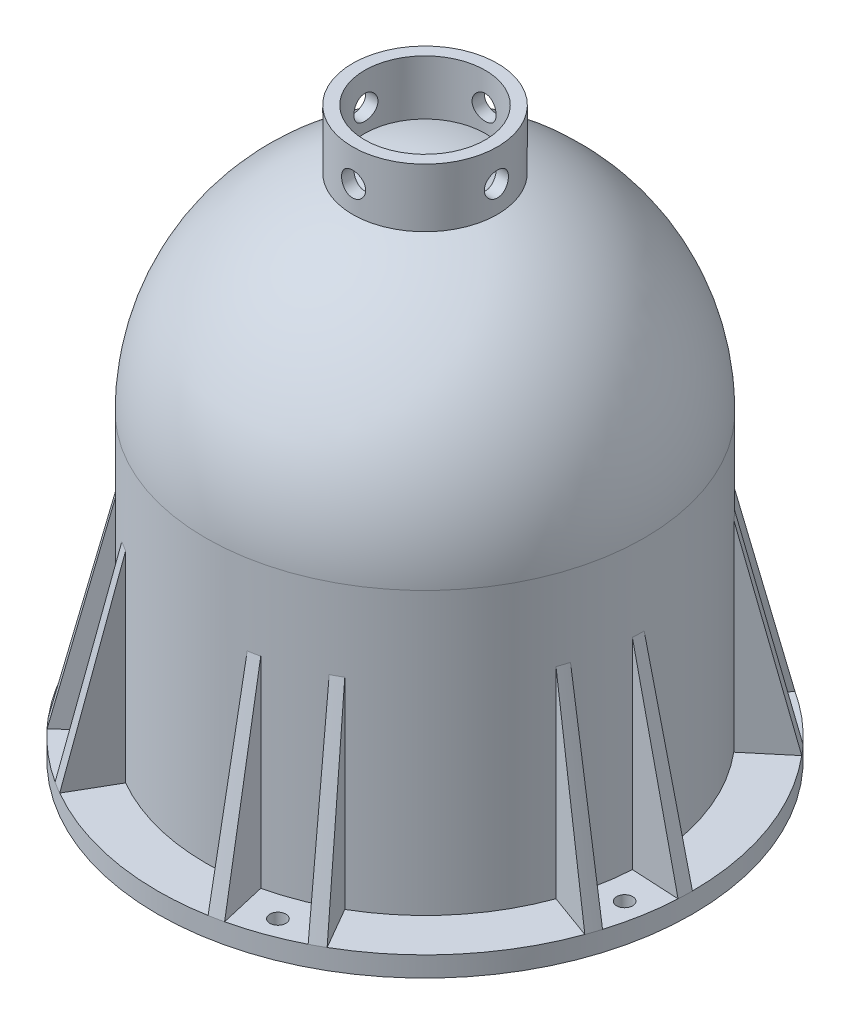
from build123d import *

# Parameters (mm, degrees)
REVOLVE2_ANGLE           = 3
CIRPATTERN1_COUNT        = 2
CIRPATTERN1_ANGLE        = 17
CUT_EXTRUDE1_REACH       = 158.028
SKETCH3_R                = 2
CIRPATTERN2_COUNT        = 6
CIRPATTERN2_COPY_1_ANGLE = 3
CIRPATTERN2_COPY_2_ANGLE = 3
CIRPATTERN2_COPY_3_ANGLE = 3
CIRPATTERN2_COPY_4_ANGLE = 3
CIRPATTERN2_COPY_5_ANGLE = 3
BOSS_EXTRUDE1_REACH      = 122.289
BOSS_EXTRUDE1_END_RADIUS = 50.5
SKETCH4_R                = 1.25
CIRPATTERN3_COUNT        = 4
BOSS_EXTRUDE2_REACH      = 171.486
BOSS_EXTRUDE2_END_RADIUS = 54.5
SKETCH5_R                = 18
SKETCH5_R_2              = 15
SKETCH6_R                = 3
CUT_EXTRUDE2_DEPTH       = 121.289234764
CIRPATTERN4_COUNT        = 2
CIRPATTERN4_ANGLE        = 90


with BuildPart() as part:
    # Sketch1 → Revolve1 (revolve)
    with BuildSketch(Plane.XY, mode=Mode.PRIVATE) as revolve1_sk:
        with BuildLine():
            Line((54.5, 0), (54.5, -70))
            Line((54.5, -70), (66.5, -70))
            Line((66.5, -70), (66.5, -75))
            Line((66.5, -75), (50.5, -75))
            Line((50.5, -75), (50.5, -70))
            Line((50.5, -70), (50.5, 0))
            ThreePointArc((50.5, 0), (35.70889245, 35.70889245), (0, 50.5))
            Line((0, 50.5), (0, 54.5))
            ThreePointArc((0, 54.5), (38.537319575, 38.537319575), (54.5, 0))
        make_face()
    revolve(revolve1_sk.sketch.rotate(Axis((0, 98.537756866, 0), (0, -1, 0)), 90), axis=Axis((0, 98.537756866, 0), (0, -1, 0)))

    # Sketch2 → Revolve2 (revolve)
    with BuildSketch(Plane.XY):
        Polygon((54.5, -20), (66.5, -70), (54.5, -70), align=None)
    revolve2 = revolve(axis=Axis((0, 98.537756866, 0), (0, -1, 0)), revolution_arc=REVOLVE2_ANGLE)

    # CirPattern1: Revolve2 ×2 about axis
    cirpattern1_axis = Axis((0, 0, 0), (0, -1, 0))
    for i in range(1, CIRPATTERN1_COUNT):
        add(revolve2.rotate(cirpattern1_axis, i * CIRPATTERN1_ANGLE / (CIRPATTERN1_COUNT - 1)))

    # Sketch3 → Cut-Extrude1 (cut, up to next)
    with BuildSketch(Plane(origin=(0, -70, 0), x_dir=(1, 0, 0), z_dir=(0, 1, 0)), mode=Mode.PRIVATE) as cut_extrude1_sk1:
        with Locations(Location((60.271959422, -10.627572626, 0), (0, 0, 270))):
            Circle(SKETCH3_R)
    cut_extrude1_tool1 = extrude(cut_extrude1_sk1.sketch, amount=-CUT_EXTRUDE1_REACH, mode=Mode.PRIVATE) & part.part
    cut_extrude1 = cut_extrude1_tool1.solids().sort_by_distance((60.271959, -70, 10.627573))[0]
    add(cut_extrude1, mode=Mode.SUBTRACT)

    # CirPattern2: Revolve2, Cut-Extrude1 ×6 about axis
    cirpattern2_axis = Axis((0, 0, 0), (0, 1, 0))
    add([revolve2.rotate(cirpattern2_axis, i * 360 / CIRPATTERN2_COUNT) for i in range(1, CIRPATTERN2_COUNT)])
    add([cut_extrude1.rotate(cirpattern2_axis, i * 360 / CIRPATTERN2_COUNT) for i in range(1, CIRPATTERN2_COUNT)], mode=Mode.SUBTRACT)

    # CirPattern2 copy 1 sketch → CirPattern2 copy 1 (revolve)
    with BuildSketch(Plane(origin=(0, 0, 0), x_dir=(0.7313537016191711, 0, -0.6819983600624979), z_dir=(0.6819983600624979, 0, 0.7313537016191711))):
        Polygon((54.5, -20), (66.5, -70), (54.5, -70), align=None)
    revolve(axis=Axis((0, 98.537756866, 0), (0, -1, 0)), revolution_arc=CIRPATTERN2_COPY_1_ANGLE)

    # CirPattern2 copy 2 sketch → CirPattern2 copy 2 (revolve)
    with BuildSketch(Plane(origin=(0, 0, 0), x_dir=(-0.2249510543438641, 0, -0.9743700647852354), z_dir=(0.9743700647852354, 0, -0.2249510543438641))):
        Polygon((54.5, -20), (66.5, -70), (54.5, -70), align=None)
    revolve(axis=Axis((0, 98.537756866, 0), (0, -1, 0)), revolution_arc=CIRPATTERN2_COPY_2_ANGLE)

    # CirPattern2 copy 3 sketch → CirPattern2 copy 3 (revolve)
    with BuildSketch(Plane(origin=(0, 0, 0), x_dir=(-0.9563047559630353, 0, -0.2923717047227375), z_dir=(0.2923717047227375, 0, -0.9563047559630353))):
        Polygon((54.5, -20), (66.5, -70), (54.5, -70), align=None)
    revolve(axis=Axis((0, 98.537756866, 0), (0, -1, 0)), revolution_arc=CIRPATTERN2_COPY_3_ANGLE)

    # CirPattern2 copy 4 sketch → CirPattern2 copy 4 (revolve)
    with BuildSketch(Plane(origin=(0, 0, 0), x_dir=(-0.7313537016191713, 0, 0.6819983600624976), z_dir=(-0.6819983600624976, 0, -0.7313537016191713))):
        Polygon((54.5, -20), (66.5, -70), (54.5, -70), align=None)
    revolve(axis=Axis((0, 98.537756866, 0), (0, -1, 0)), revolution_arc=CIRPATTERN2_COPY_4_ANGLE)

    # CirPattern2 copy 5 sketch → CirPattern2 copy 5 (revolve)
    with BuildSketch(Plane(origin=(0, 0, 0), x_dir=(0.22495105434386448, 0, 0.9743700647852354), z_dir=(-0.9743700647852354, 0, 0.22495105434386448))):
        Polygon((54.5, -20), (66.5, -70), (54.5, -70), align=None)
    revolve(axis=Axis((0, 98.537756866, 0), (0, -1, 0)), revolution_arc=CIRPATTERN2_COPY_5_ANGLE)

    # Boss-Extrude1: up to this sphere (the profile starts inside it)
    boss_extrude1_end = Location((0, 0, 0)) * Sphere(BOSS_EXTRUDE1_END_RADIUS, mode=Mode.PRIVATE)
    # Sketch4 → Boss-Extrude1 (add, up to the surface)
    with BuildSketch(Plane(origin=(0, 0, 0), x_dir=(1, 0, 0), z_dir=(0, 1, 0)), mode=Mode.PRIVATE) as boss_extrude1_sk1:
        with BuildLine():
            Line((-33.760137444, -28.5520382), (-41.653704692, -28.5520382))
            ThreePointArc((-41.653704692, -28.5520382), (-40.56955385, -30.072600493), (-39.429923731, -31.5520382))
            Line((-39.429923731, -31.5520382), (-33.760137444, -31.5520382))
            ThreePointArc((-33.760137444, -31.5520382), (-32.880465325, -32.880465325), (-31.5520382, -33.760137444))
            Line((-31.5520382, -33.760137444), (-31.5520382, -39.429923731))
            ThreePointArc((-31.5520382, -39.429923731), (-30.072600493, -40.56955385), (-28.5520382, -41.653704692))
            Line((-28.5520382, -41.653704692), (-28.5520382, -33.760137444))
            ThreePointArc((-28.5520382, -33.760137444), (-27.223611076, -27.223611076), (-33.760137444, -28.5520382))
        make_face()
        with Locations(Location((-30.0520382, -30.0520382, 0), (0, 0, 225))):
            Circle(SKETCH4_R, mode=Mode.SUBTRACT)
    boss_extrude1_tool1 = extrude(boss_extrude1_sk1.sketch, amount=BOSS_EXTRUDE1_REACH, mode=Mode.PRIVATE) & boss_extrude1_end
    boss_extrude1 = boss_extrude1_tool1.solids().sort_by_distance((-31.722169, 0, 31.722169))[0]
    add(boss_extrude1)

    # CirPattern3: Boss-Extrude1 ×4 about axis
    cirpattern3_axis = Axis((0, 0, 0), (0, 1, 0))
    for i in range(1, CIRPATTERN3_COUNT):
        add(boss_extrude1.rotate(cirpattern3_axis, i * 360 / CIRPATTERN3_COUNT))

    # Boss-Extrude2: up to this sphere (the profile starts outside it)
    boss_extrude2_end = Location((0, 0, 0)) * Sphere(BOSS_EXTRUDE2_END_RADIUS, mode=Mode.PRIVATE)
    # Sketch5 → Boss-Extrude2 (add, up to the surface)
    with BuildSketch(Plane(origin=(0, 66, 0), x_dir=(1, 0, 0), z_dir=(0, 1, 0)), mode=Mode.PRIVATE) as boss_extrude2_sk1:
        with Locations(Location((0, 0, 0), (0, 0, 270))):
            Circle(SKETCH5_R)
        with Locations(Location((0, 0, 0), (0, 0, 270))):
            Circle(SKETCH5_R_2, mode=Mode.SUBTRACT)
    boss_extrude2_tool1 = extrude(boss_extrude2_sk1.sketch, amount=-BOSS_EXTRUDE2_REACH, mode=Mode.PRIVATE) - boss_extrude2_end
    add(boss_extrude2_tool1.solids().sort_by_distance((0, 66, -17.490883))[0])

    # Sketch6 → Cut-Extrude2 (cut, symmetric)
    with BuildSketch(Plane.XY):
        with Locations((0, 58)):
            Circle(SKETCH6_R)
    cut_extrude2 = extrude(amount=CUT_EXTRUDE2_DEPTH, both=True, mode=Mode.SUBTRACT)

    # CirPattern4: Cut-Extrude2 ×2 about axis
    cirpattern4_axis = Axis((0, 98.537756866, 0), (0, -1, 0))
    for i in range(1, CIRPATTERN4_COUNT):
        add(cut_extrude2.rotate(cirpattern4_axis, i * CIRPATTERN4_ANGLE / (CIRPATTERN4_COUNT - 1)), mode=Mode.SUBTRACT)


solid = part.part
